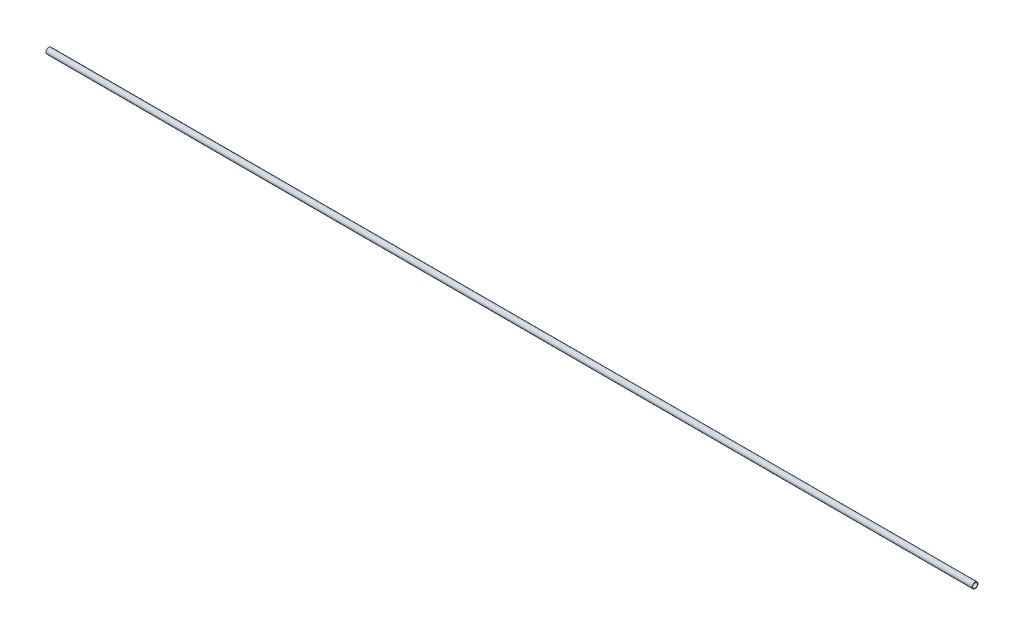
from build123d import *

# Parameters (mm, degrees)
SKETCH1_R           = 3.81
BOSS_EXTRUDE1_DEPTH = 1219.2
SKETCH2_R           = 3.175
CUT_EXTRUDE1_DEPTH  = 1220.2


with BuildPart() as part:
    # Sketch1 → Boss-Extrude1 (new body)
    with BuildSketch(Plane(origin=(0, 0, 0), x_dir=(0, 0, -1), z_dir=(1, 0, 0))):
        Circle(SKETCH1_R)
    extrude(amount=BOSS_EXTRUDE1_DEPTH)

    # Sketch2 → Cut-Extrude1 (cut, through all)
    with BuildSketch(Plane.ZY):
        Circle(SKETCH2_R)
    extrude(amount=-CUT_EXTRUDE1_DEPTH, mode=Mode.SUBTRACT)


solid = part.part
